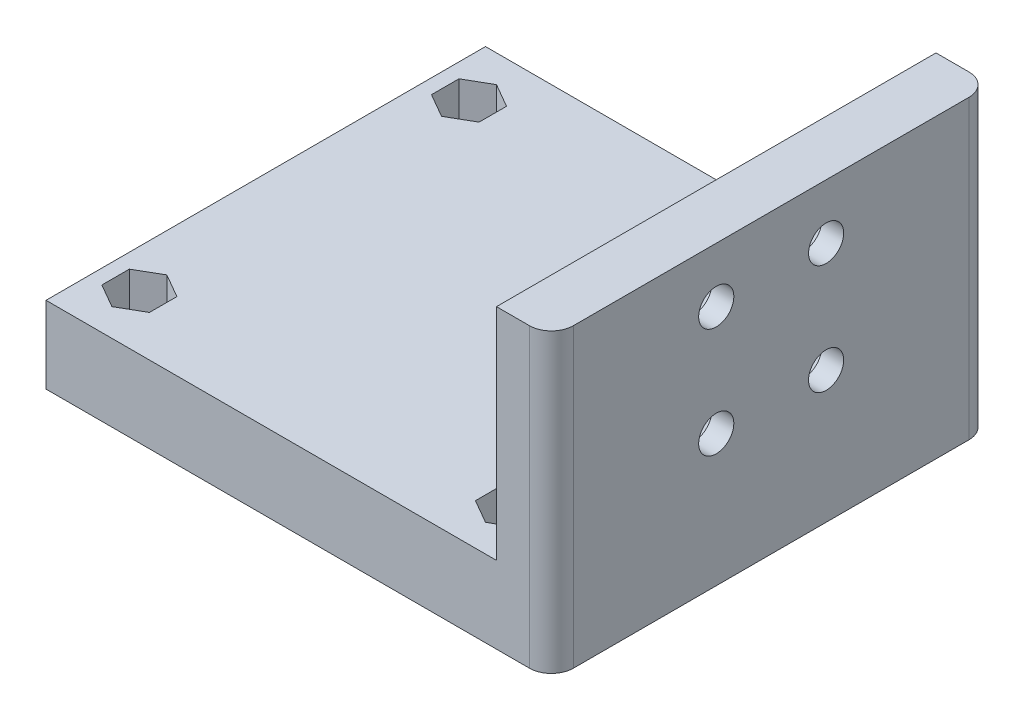
from build123d import *

# Parameters (mm, degrees)
ESQUISSE1_W             = 5
ESQUISSE1_H             = 40
BOSS_EXTRU_1_DEPTH      = 27
ESQUISSE2_W             = 40
ESQUISSE2_H             = 7
BOSS_EXTRU_2_DEPTH      = 41
CONG_1_R                = 2
ENL_V_MAT_EXTRU_1_REACH = 48
ESQUISSE4_R             = 1.6
ENL_V_MAT_EXTRU_3_DEPTH = 3
ESQUISSE9_R             = 1.1
ENL_V_MAT_EXTRU_5_DEPTH = 8
ENL_V_MAT_EXTRU_4_DEPTH = 4


with BuildPart() as part:
    # Esquisse1 → Boss.-Extru.1 (new body)
    with BuildSketch(Plane(origin=(0, 0, 0), x_dir=(1, 0, 0), z_dir=(0, 1, 0))):
        with Locations((-2.5, 0)):
            Rectangle(ESQUISSE1_W, ESQUISSE1_H)
    extrude(amount=-BOSS_EXTRU_1_DEPTH)

    # Esquisse2 → Boss.-Extru.2 (add)
    with BuildSketch(Plane.ZY.offset(5)):
        with Locations((0, -23.5)):
            Rectangle(ESQUISSE2_W, ESQUISSE2_H)
    extrude(amount=BOSS_EXTRU_2_DEPTH)

    # Congé1
    cong_1_edges = [part.edges().sort_by_distance(p)[0] for p in [
        (0, -13.5, 20),
        (0, -13.5, -20),
    ]]
    fillet(cong_1_edges, radius=CONG_1_R)

    # Esquisse4 → Enlèv. mat.-Extru.1 (cut, up to next)
    with BuildSketch(Plane(origin=(0, 0, 0), x_dir=(0, 0, -1), z_dir=(1, 0, 0)), mode=Mode.PRIVATE) as enl_v_mat_extru_1_sk1:
        with Locations((-5, -5)):
            Circle(ESQUISSE4_R)
    enl_v_mat_extru_1_tool1 = extrude(enl_v_mat_extru_1_sk1.sketch, amount=-ENL_V_MAT_EXTRU_1_REACH, mode=Mode.PRIVATE) & part.part
    add(enl_v_mat_extru_1_tool1.solids().sort_by_distance((0, -5, 5))[0], mode=Mode.SUBTRACT)
    # Esquisse4 → Enlèv. mat.-Extru.1 (cut, up to next)
    with BuildSketch(Plane(origin=(0, 0, 0), x_dir=(0, 0, -1), z_dir=(1, 0, 0)), mode=Mode.PRIVATE) as enl_v_mat_extru_1_sk2:
        with Locations((5, -5)):
            Circle(ESQUISSE4_R)
    enl_v_mat_extru_1_tool2 = extrude(enl_v_mat_extru_1_sk2.sketch, amount=-ENL_V_MAT_EXTRU_1_REACH, mode=Mode.PRIVATE) & part.part
    add(enl_v_mat_extru_1_tool2.solids().sort_by_distance((0, -5, -5))[0], mode=Mode.SUBTRACT)
    # Esquisse4 → Enlèv. mat.-Extru.1 (cut, up to next)
    with BuildSketch(Plane(origin=(0, 0, 0), x_dir=(0, 0, -1), z_dir=(1, 0, 0)), mode=Mode.PRIVATE) as enl_v_mat_extru_1_sk3:
        with Locations((-5, -15)):
            Circle(ESQUISSE4_R)
    enl_v_mat_extru_1_tool3 = extrude(enl_v_mat_extru_1_sk3.sketch, amount=-ENL_V_MAT_EXTRU_1_REACH, mode=Mode.PRIVATE) & part.part
    add(enl_v_mat_extru_1_tool3.solids().sort_by_distance((0, -15, 5))[0], mode=Mode.SUBTRACT)
    # Esquisse4 → Enlèv. mat.-Extru.1 (cut, up to next)
    with BuildSketch(Plane(origin=(0, 0, 0), x_dir=(0, 0, -1), z_dir=(1, 0, 0)), mode=Mode.PRIVATE) as enl_v_mat_extru_1_sk4:
        with Locations((5, -15)):
            Circle(ESQUISSE4_R)
    enl_v_mat_extru_1_tool4 = extrude(enl_v_mat_extru_1_sk4.sketch, amount=-ENL_V_MAT_EXTRU_1_REACH, mode=Mode.PRIVATE) & part.part
    add(enl_v_mat_extru_1_tool4.solids().sort_by_distance((0, -15, -5))[0], mode=Mode.SUBTRACT)

    # Esquisse7 → Enlèv. mat.-Extru.3 (cut)
    with BuildSketch(Plane.ZY.offset(5)):
        Polygon((-3.25, -8.031088913), (-1.5, -5), (-3.25, -1.968911087), (-6.75, -1.968911087), (-8.5, -5), (-6.75, -8.031088913), align=None)
        Polygon((3.25, -1.968911087), (1.5, -5), (3.25, -8.031088913), (6.75, -8.031088913), (8.5, -5), (6.75, -1.968911087), align=None)
        Polygon((-3.25, -18.031088913), (-1.5, -15), (-3.25, -11.968911087), (-6.75, -11.968911087), (-8.5, -15), (-6.75, -18.031088913), align=None)
        Polygon((8.5, -15), (6.75, -11.968911087), (3.25, -11.968911087), (1.5, -15), (3.25, -18.031088913), (6.75, -18.031088913), align=None)
    extrude(amount=-ENL_V_MAT_EXTRU_3_DEPTH, mode=Mode.SUBTRACT)

    # Esquisse9 → Enlèv. mat.-Extru.5 (cut, through all)
    with BuildSketch(Plane(origin=(0, -20, 0), x_dir=(1, 0, 0), z_dir=(0, 1, 0))):
        with Locations(Location((-8.5, 15, 0), (0, 0, 270))):  # turned: the seam where the file's is
            Circle(ESQUISSE9_R)
        with Locations(Location((-8.5, -15, 0), (0, 0, 270))):  # turned: the seam where the file's is
            Circle(ESQUISSE9_R)
        with Locations(Location((-42.5, -15, 0), (0, 0, 270))):  # turned: the seam where the file's is
            Circle(ESQUISSE9_R)
        with Locations(Location((-42.5, 15, 0), (0, 0, 270))):  # turned: the seam where the file's is
            Circle(ESQUISSE9_R)
    extrude(amount=-ENL_V_MAT_EXTRU_5_DEPTH, mode=Mode.SUBTRACT)

    # Esquisse8 → Enlèv. mat.-Extru.4 (cut)
    with BuildSketch(Plane(origin=(0, -20, 0), x_dir=(1, 0, 0), z_dir=(0, 1, 0))):
        Polygon((-10.665063509, 13.75), (-8.5, 12.5), (-6.334936491, 13.75), (-6.334936491, 16.25), (-8.5, 17.5), (-10.665063509, 16.25), align=None)
        Polygon((-10.665063509, -16.25), (-8.5, -17.5), (-6.334936491, -16.25), (-6.334936491, -13.75), (-8.5, -12.5), (-10.665063509, -13.75), align=None)
        Polygon((-44.665063509, -16.25), (-42.5, -17.5), (-40.334936491, -16.25), (-40.334936491, -13.75), (-42.5, -12.5), (-44.665063509, -13.75), align=None)
        Polygon((-42.5, 12.5), (-40.334936491, 13.75), (-40.334936491, 16.25), (-42.5, 17.5), (-44.665063509, 16.25), (-44.665063509, 13.75), align=None)
    extrude(amount=-ENL_V_MAT_EXTRU_4_DEPTH, mode=Mode.SUBTRACT)


solid = part.part
